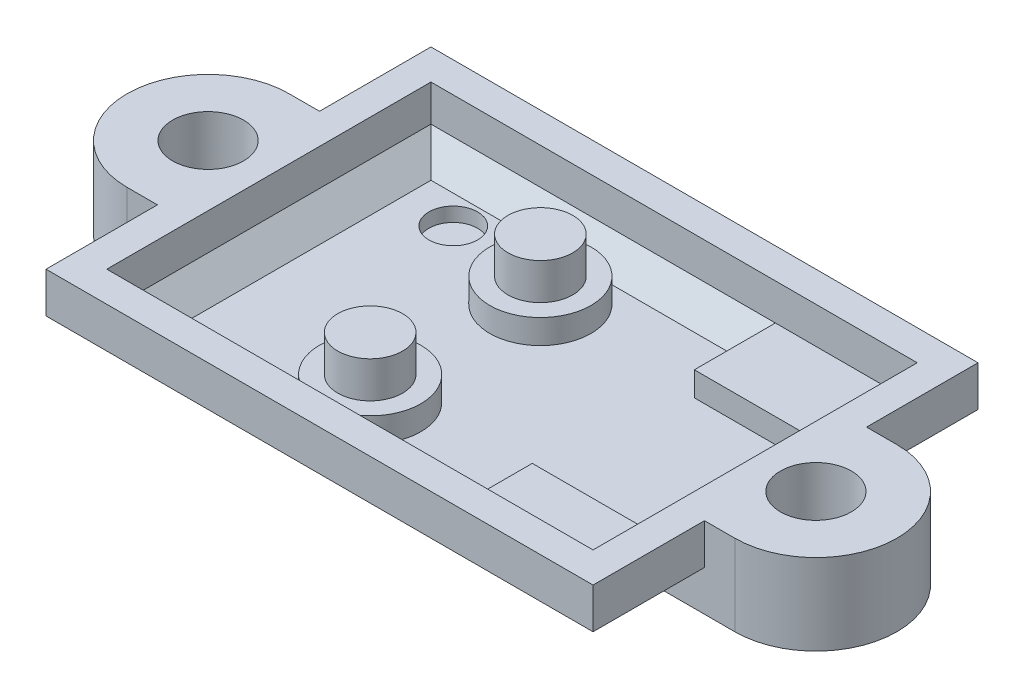
from build123d import *

# Parameters (mm, degrees)
SKETCH_398_R        = 1.75
EXTRUDE_1_DEPTH     = 4
CHAMFER_1_SIZE      = 1.5
SKETCH_632_W        = 24
SKETCH_632_H        = 16
SKETCH_632_R        = 1.6
CUT_EXTRUDE_1_DEPTH = 3
SKETCH_910_R        = 2.5
SKETCH_910_W        = 7
SKETCH_910_H        = 4
EXTRUDE_2_DEPTH     = 1.2
SKETCH_1130_R       = 1.2
CUT_EXTRUDE_2_DEPTH = 0.7
CHAMFER_2_SIZE      = 1.2
CHAMFER_3_SIZE      = 2


with BuildPart() as part:
    # Sketch 398 → Бобышка-Вытянуть1 (new body)
    with BuildSketch(Plane(origin=(0, 0, 0), x_dir=(1, 0, 0), z_dir=(0, 1, 0))):
        with BuildLine():
            Line((-15, 4), (-13.5, 4))
            Line((-13.5, 4), (-13.5, 9.5))
            Line((-13.5, 9.5), (13.5, 9.5))
            Line((13.5, 9.5), (13.5, 4))
            Line((13.5, 4), (15, 4))
            ThreePointArc((15, 4), (19, 0), (15, -4))
            Line((15, -4), (13.5, -4))
            Line((13.5, -4), (13.5, -9.5))
            Line((13.5, -9.5), (-13.5, -9.5))
            Line((-13.5, -9.5), (-13.5, -4))
            Line((-13.5, -4), (-15, -4))
            ThreePointArc((-15, -4), (-19, 0), (-15, 4))
        make_face()
        with Locations((-15, 0)):
            Circle(SKETCH_398_R, mode=Mode.SUBTRACT)
        with Locations((15, 0)):
            Circle(SKETCH_398_R, mode=Mode.SUBTRACT)
    extrude(amount=EXTRUDE_1_DEPTH)

    # Фаска1
    chamfer_1_edges = [part.edges().sort_by_distance(p)[0] for p in [
        (13.25, 0, 0),
        (-16.75, 0, 0),
    ]]
    chamfer(chamfer_1_edges, length=CHAMFER_1_SIZE)

    # Sketch 632 → Вырез-Вытянуть1 (cut)
    with BuildSketch(Plane(origin=(0, 4, 0), x_dir=(1, 0, 0), z_dir=(0, 1, 0))):
        Rectangle(SKETCH_632_W, SKETCH_632_H)
        with Locations((-2.8, 4.2)):
            Circle(SKETCH_632_R, mode=Mode.SUBTRACT)
        with Locations((-2.8, -4.2)):
            Circle(SKETCH_632_R, mode=Mode.SUBTRACT)
    extrude(amount=-CUT_EXTRUDE_1_DEPTH, mode=Mode.SUBTRACT)

    # Sketch 910 → Бобышка-Вытянуть2 (add)
    with BuildSketch(Plane(origin=(0, 1, 0), x_dir=(1, 0, 0), z_dir=(0, 1, 0))):
        with Locations((-2.8, -4.2)):
            Circle(SKETCH_910_R)
        with Locations((-2.8, 4.2)):
            Circle(SKETCH_910_R)
        with Locations((8.5, -6)):
            Rectangle(SKETCH_910_W, SKETCH_910_H)
        with Locations((8.5, 6)):
            Rectangle(SKETCH_910_W, SKETCH_910_H)
    extrude(amount=EXTRUDE_2_DEPTH)

    # Sketch 1130 → Вырез-Вытянуть2 (cut)
    with BuildSketch(Plane(origin=(0, 1, 0), x_dir=(1, 0, 0), z_dir=(0, 1, 0))):
        with Locations((-8.3, 5.4)):
            Circle(SKETCH_1130_R)
    extrude(amount=-CUT_EXTRUDE_2_DEPTH, mode=Mode.SUBTRACT)

    # Фаска2
    chamfer_2_edges = [part.edges().sort_by_distance(p)[0] for p in [
        (12, 1, 0),
        (-3.5, 1, -8),
        (-12, 1, 0),
        (-3.5, 1, 8),
    ]]
    chamfer(chamfer_2_edges, length=CHAMFER_2_SIZE)

    # Фаска3
    chamfer_3_edges = [part.edges().sort_by_distance(p)[0] for p in [
        (0, 0, -9.5),
        (13.5, 0, -6.75),
        (13.5, 0, 6.75),
        (0, 0, 9.5),
        (-13.5, 0, 6.75),
        (-13.5, 0, -6.75),
    ]]
    chamfer(chamfer_3_edges, length=CHAMFER_3_SIZE)


solid = part.part
